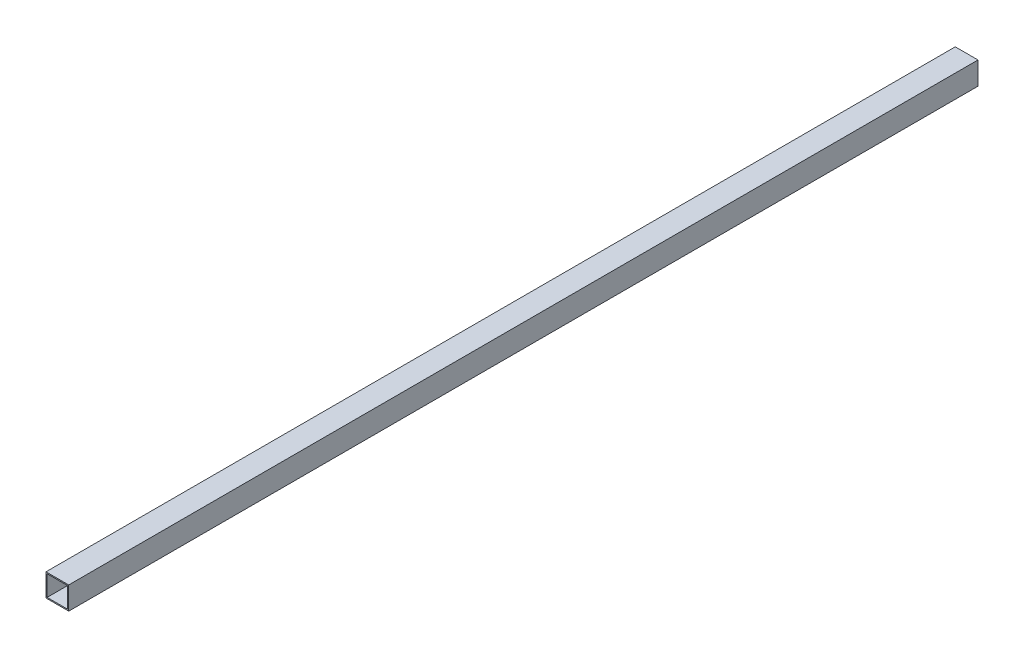
from build123d import *

# Parameters (mm, degrees)
SKETCH_1_W      = 10
SKETCH_1_H      = 10
SKETCH_1_W_2    = 9
SKETCH_1_H_2    = 9
EXTRUDE_1_DEPTH = 400


with BuildPart() as part:
    # Эскиз1 → Бобышка-Вытянуть1 (new body)
    with BuildSketch(Plane.XY):
        Rectangle(SKETCH_1_W, SKETCH_1_H)
        Rectangle(SKETCH_1_W_2, SKETCH_1_H_2, mode=Mode.SUBTRACT)
    extrude(amount=EXTRUDE_1_DEPTH)


solid = part.part
